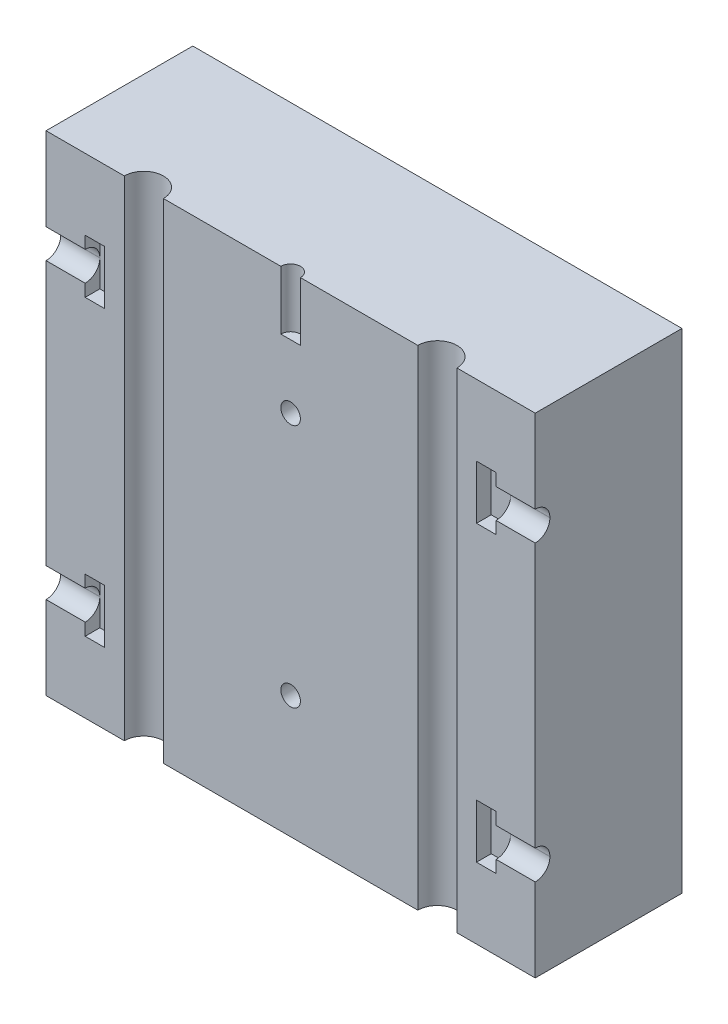
from build123d import *

# Parameters (mm, degrees)
ESQUISSE1_W             = 50
ESQUISSE1_H             = 50
EXTRUSION1_DEPTH        = 15
ESQUISSE2_R             = 2
ENL_V_MAT_EXTRU_1_DEPTH = 51
ENL_V_MAT_EXTRU_3_DEPTH = 1.5
CONG_1_R                = 1.49
CONG_2_R                = 1.49
ESQUISSE4_R             = 1
ENL_V_MAT_EXTRU_4_DEPTH = 6
ESQUISSE5_R             = 1
ENL_V_MAT_EXTRU_5_DEPTH = 6


with BuildPart() as part:
    # Esquisse1 → Extrusion1 (new body)
    with BuildSketch(Plane.XY):
        with Locations((25, 25)):
            Rectangle(ESQUISSE1_W, ESQUISSE1_H)
    extrude(amount=EXTRUSION1_DEPTH)

    # Esquisse2 → Enlèv. mat.-Extru.1 (cut, through all)
    with BuildSketch(Plane(origin=(0, 50, 0), x_dir=(-1, 0, 0), z_dir=(0, 1, 0))):
        with Locations((-10, 15)):
            Circle(ESQUISSE2_R)
        with Locations((-40, 15)):
            Circle(ESQUISSE2_R)
    extrude(amount=-ENL_V_MAT_EXTRU_1_DEPTH, mode=Mode.SUBTRACT)

    # Esquisse3 → Enlèv. mat.-Extru.3 (cut)
    with BuildSketch(Plane.XY.offset(15)):
        Polygon((-1.134972747, 11.5), (4, 11.5), (4, 12.75), (6, 12.75), (6, 7.25), (4, 7.25), (4, 8.5), (-1.134972747, 8.5), align=None)
        Polygon((-1.134972747, 38.5), (-1.134972747, 41.5), (4, 41.5), (4, 42.75), (6, 42.75), (6, 37.25), (4, 37.25), (4, 38.5), align=None)
        Polygon((46, 42.75), (44, 42.75), (44, 37.25), (46, 37.25), (46, 38.5), (51.134972747, 38.5), (51.134972747, 41.5), (46, 41.5), align=None)
        Polygon((46, 12.75), (44, 12.75), (44, 7.25), (46, 7.25), (46, 8.5), (51.134972747, 8.5), (51.134972747, 11.5), (46, 11.5), align=None)
    extrude(amount=-ENL_V_MAT_EXTRU_3_DEPTH, mode=Mode.SUBTRACT)

    # Congé1
    cong_1_edges = [part.edges().sort_by_distance(p)[0] for p in [
        (2, 11.5, 13.5),
    ]]
    fillet(cong_1_edges, radius=CONG_1_R)

    # Congé2
    cong_2_edges = [part.edges().sort_by_distance(p)[0] for p in [
        (48, 11.5, 13.5),
        (48, 8.5, 13.5),
        (2, 8.5, 13.5),
        (2, 38.5, 13.5),
        (2, 41.5, 13.5),
        (48, 41.5, 13.5),
        (48, 38.5, 13.5),
    ]]
    fillet(cong_2_edges, radius=CONG_2_R)

    # Esquisse4 → Enlèv. mat.-Extru.4 (cut)
    with BuildSketch(Plane(origin=(0, 50, 0), x_dir=(-1, 0, 0), z_dir=(0, 1, 0))):
        with Locations((-25, 15)):
            Circle(ESQUISSE4_R)
    extrude(amount=-ENL_V_MAT_EXTRU_4_DEPTH, mode=Mode.SUBTRACT)

    # Esquisse5 → Enlèv. mat.-Extru.5 (cut)
    with BuildSketch(Plane.XY.offset(15)):
        with Locations((25, 37.5)):
            Circle(ESQUISSE5_R)
        with Locations(Location((25, 12.5, 0), (0, 0, 180))):  # turned: the seam where the file's is
            Circle(ESQUISSE5_R)
    extrude(amount=-ENL_V_MAT_EXTRU_5_DEPTH, mode=Mode.SUBTRACT)


solid = part.part
